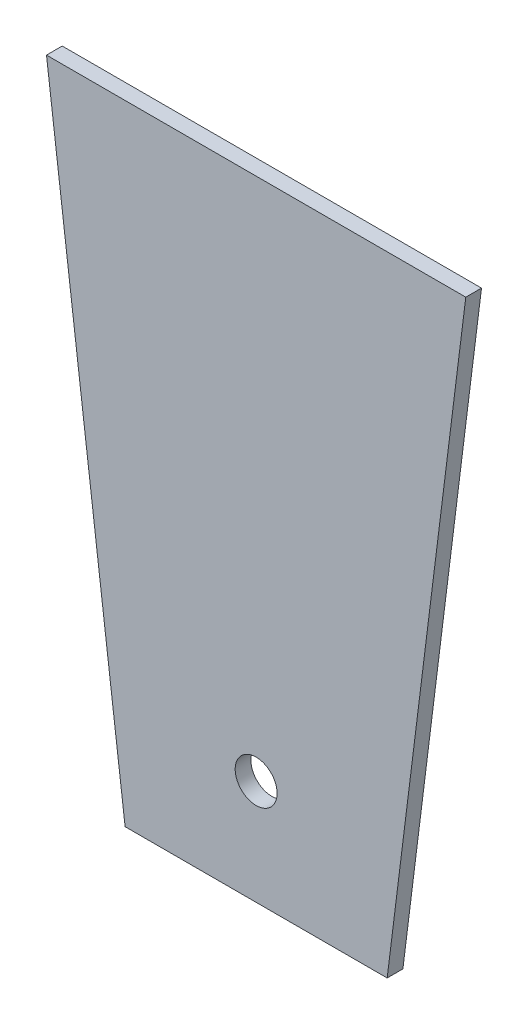
from build123d import *

# Parameters (mm, degrees)
SKETCH1_R           = 4
BOSS_EXTRUDE1_DEPTH = 3


with BuildPart() as part:
    # Sketch1 → Boss-Extrude1 (new body)
    with BuildSketch(Plane.XY):
        Polygon((-40, 120), (40, 120), (25, 0), (-25, 0), align=None)
        with Locations((0, 20)):
            Circle(SKETCH1_R, mode=Mode.SUBTRACT)
    extrude(amount=BOSS_EXTRUDE1_DEPTH)


solid = part.part
